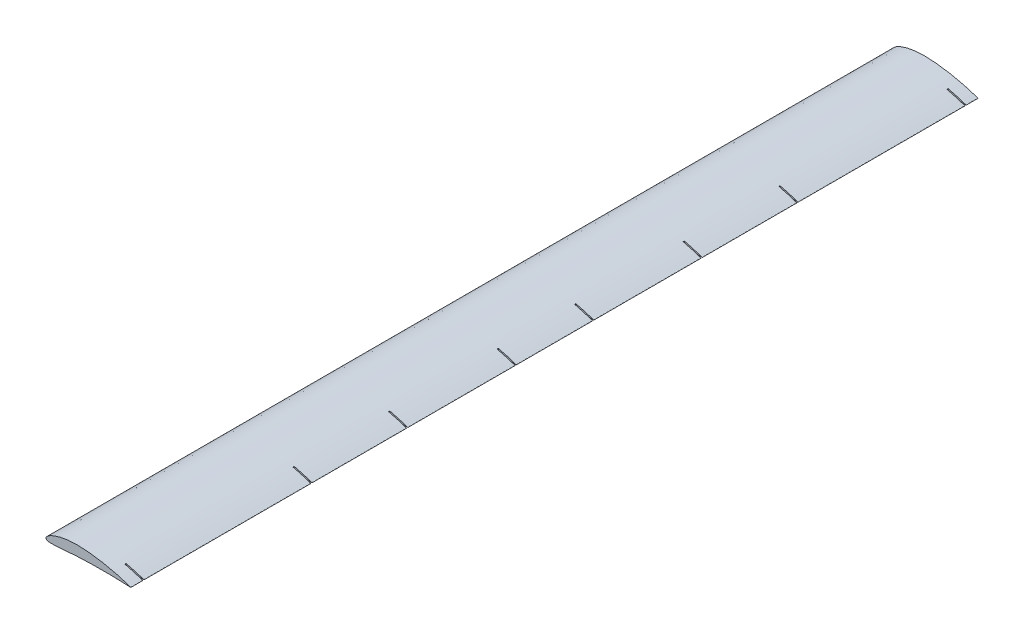
from build123d import *

# Parameters (mm, degrees)
BOSS_EXTRUDE1_DEPTH     = 3553
SKETCH4_W               = 150
SKETCH4_H               = 5
CUT_EXTRUDE1_DEPTH      = 130
CUT_EXTRUDE1_DEPTH_BACK = 611


with BuildPart() as part:
    # Sketch1 → Boss-Extrude1 (new body)
    with BuildSketch(Plane.XY):
        with BuildLine():
            Line((355.388825, 0.440572), (355.3, 0))
            add(Edge.make_bspline(
                [(355.388825, 0.440572), (355.072603286, 0.549516623), (353.812680399, 0.983584931), (350.992407292, 1.956895199), (346.315725137, 3.527230185), (339.832005579, 5.665122746), (331.596554959, 8.282871195), (321.686327859, 11.298849019), (310.198614019, 14.618532306), (297.243823465, 18.13744368), (282.952476578, 21.749440888), (267.468177612, 25.340319127), (250.956588017, 28.819942371), (233.590078698, 32.075633139), (215.555937335, 35.01162716), (197.052174744, 37.551684071), (178.28669983, 39.614243835), (159.460829543, 41.133845778), (140.659584374, 42.131776065), (122.083987059, 42.24923011), (103.993639545, 41.341634903), (86.763912143, 39.49969142), (70.622731212, 36.83211996), (55.782512937, 33.455335468), (42.429267609, 29.534201303), (30.719080351, 25.244475907), (20.777956894, 20.759719282), (12.700035896, 16.252744389), (6.521176104, 11.882818867), (2.274496134, 7.744944864), (-0.169994053, 3.826119792), (-0.391591817, -0.118040401), (1.946436079, -3.277919037), (6.045170701, -5.256598628), (11.680387282, -6.555673561), (18.940492419, -7.236577278), (27.753137312, -7.372892679), (38.033962449, -7.021896944), (49.667261337, -6.270142529), (62.533566871, -5.206559414), (76.507765945, -3.95272966), (91.463931719, -2.61585053), (107.272494382, -1.311837337), (123.802197121, -0.161903933), (141.047579469, 0.704627534), (158.855104007, 1.316693166), (177.038266255, 1.947694677), (195.280716626, 2.451761084), (213.378921527, 2.816775729), (231.139857508, 3.021497726), (248.367929653, 3.058022354), (264.871099533, 2.937017605), (280.463332407, 2.685994666), (294.964786361, 2.312606477), (308.205548185, 1.881943495), (320.034302084, 1.401004204), (330.285883706, 0.942938799), (338.905389171, 0.456997225), (345.591917768, 0.221724024), (350.741360919, -0.376049708), (353.293292622, -0.00512943), (355.257302226, -0.727689162), (355.289895195, -0.172214059), (355.3, 0)],
                knots=[0, 0, 0, 0, 0.001371577, 0.005464776, 0.012234802, 0.021601969, 0.033461345, 0.04767125, 0.064081318, 0.082496261, 0.102719149, 0.124527079, 0.147675648, 0.171912573, 0.19697838, 0.222596912, 0.248496767, 0.274385101, 0.300041178, 0.325689988, 0.350525088, 0.374279703, 0.396711254, 0.417576734, 0.436654006, 0.45374439, 0.468679994, 0.481329415, 0.491630702, 0.499615789, 0.505546281, 0.510184984, 0.514824194, 0.520701508, 0.52851604, 0.538465752, 0.550542609, 0.564643256, 0.580638139, 0.598344876, 0.617584458, 0.638174401, 0.65992209, 0.682632113, 0.706120665, 0.730727383, 0.755700244, 0.780731769, 0.805564463, 0.829932396, 0.853570292, 0.876213105, 0.897609987, 0.917519394, 0.935698347, 0.951942678, 0.966047159, 0.97783994, 0.987174002, 0.993931501, 0.998018399, 0.999385644, 1, 1, 1, 1], degree=3))
        make_face()
    extrude(amount=BOSS_EXTRUDE1_DEPTH)

    # Sketch4 → Cut-Extrude1 (cut, two sides)
    with BuildSketch(Plane(origin=(0, 0, 0), x_dir=(1, 0, 0), z_dir=(0, 1, 0))) as cut_extrude1_sk:
        with Locations((355.388825, -52.5)):
            Rectangle(SKETCH4_W, SKETCH4_H)
        with Locations((355.388825, -757.5)):
            Rectangle(SKETCH4_W, SKETCH4_H)
        with Locations((355.388825, -1159)):
            Rectangle(SKETCH4_W, SKETCH4_H)
        with Locations((355.388825, -1614)):
            Rectangle(SKETCH4_W, SKETCH4_H)
        with Locations((355.388825, -1939)):
            Rectangle(SKETCH4_W, SKETCH4_H)
        with Locations((355.388825, -2394)):
            Rectangle(SKETCH4_W, SKETCH4_H)
        with Locations((355.388825, -2795.5)):
            Rectangle(SKETCH4_W, SKETCH4_H)
        with Locations((355.388825, -3500.5)):
            Rectangle(SKETCH4_W, SKETCH4_H)
    extrude(amount=CUT_EXTRUDE1_DEPTH, mode=Mode.SUBTRACT)
    extrude(cut_extrude1_sk.sketch, amount=-CUT_EXTRUDE1_DEPTH_BACK, mode=Mode.SUBTRACT)


solid = part.part
